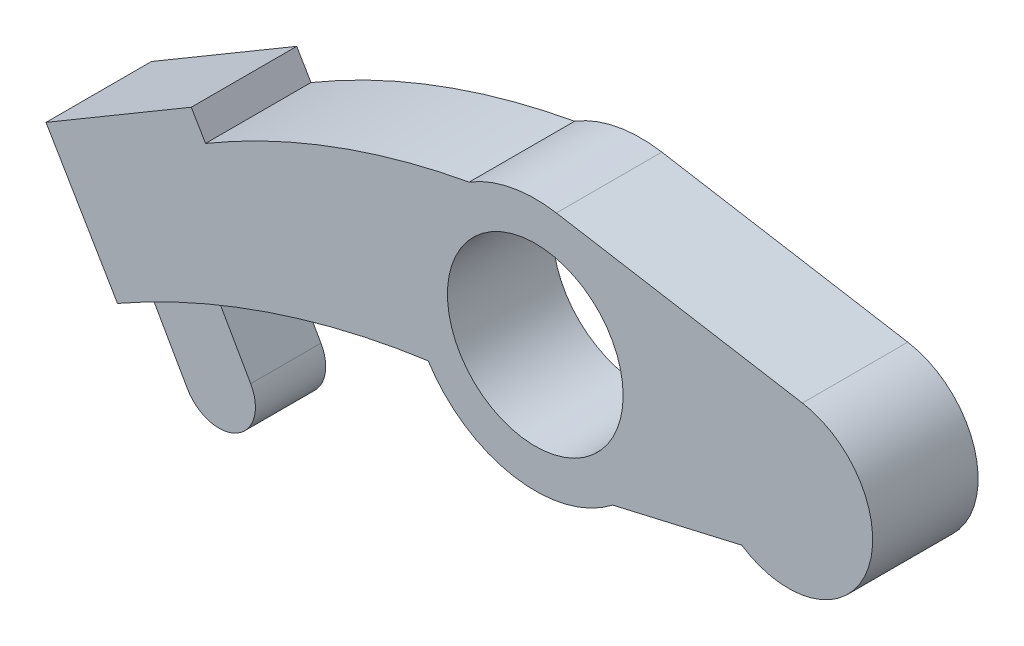
from build123d import *

# Parameters (mm, degrees)
SKETCH1_R           = 6.25
BOSS_EXTRUDE1_DEPTH = 3.75
BOSS_EXTRUDE2_DEPTH = 2.5


with BuildPart() as part:
    # Sketch1 → Boss-Extrude1 (new body, symmetric)
    with BuildSketch(Plane.XY):
        with BuildLine():
            ThreePointArc((14.68337521, -5), (23.5795956, -2.206380053), (19, 5.916079783))
            Line((19, 5.916079783), (1.5, 8.874119675))
            ThreePointArc((1.5, 8.874119675), (-1.711171484, 8.835830021), (-4.704473056, 7.672544119))
            ThreePointArc((-4.704473056, 7.672544119), (-14.388421791, 5.006214545), (-23.453994607, 0.681452586))
            Line((-23.453994607, 0.681452586), (-24.470827362, 2.403675322))
            Line((-24.470827362, 2.403675322), (-34.804163773, -3.697321205))
            Line((-34.804163773, -3.697321205), (-29.72, -12.308434881))
            ThreePointArc((-29.72, -12.308434881), (-19.025686771, -7.501050673), (-7.617535769, -4.793031276))
            ThreePointArc((-7.617535769, -4.793031276), (-1.570247279, -8.861959348), (5.50692712, -7.118549971))
            Line((5.50692712, -7.118549971), (14.68337521, -5))
        make_face()
        Circle(SKETCH1_R, mode=Mode.SUBTRACT)
    extrude(amount=BOSS_EXTRUDE1_DEPTH, both=True)

    # Sketch2 → Boss-Extrude2 (add, symmetric)
    with BuildSketch(Plane.XY):
        with BuildLine():
            Line((-28.63346637, -11.690418156), (-24.131806399, -9.129888895))
            Line((-24.131806399, -9.129888895), (-23.968684666, -9.421327611))
            Line((-23.968684666, -9.421327611), (-21.496617767, -13.767462129))
            ThreePointArc((-21.496617767, -13.767462129), (-22.466751825, -17.296987603), (-25.996277299, -16.326853546))
            Line((-25.996277299, -16.326853546), (-28.63346637, -11.690418156))
        make_face()
    extrude(amount=BOSS_EXTRUDE2_DEPTH, both=True)


solid = part.part
